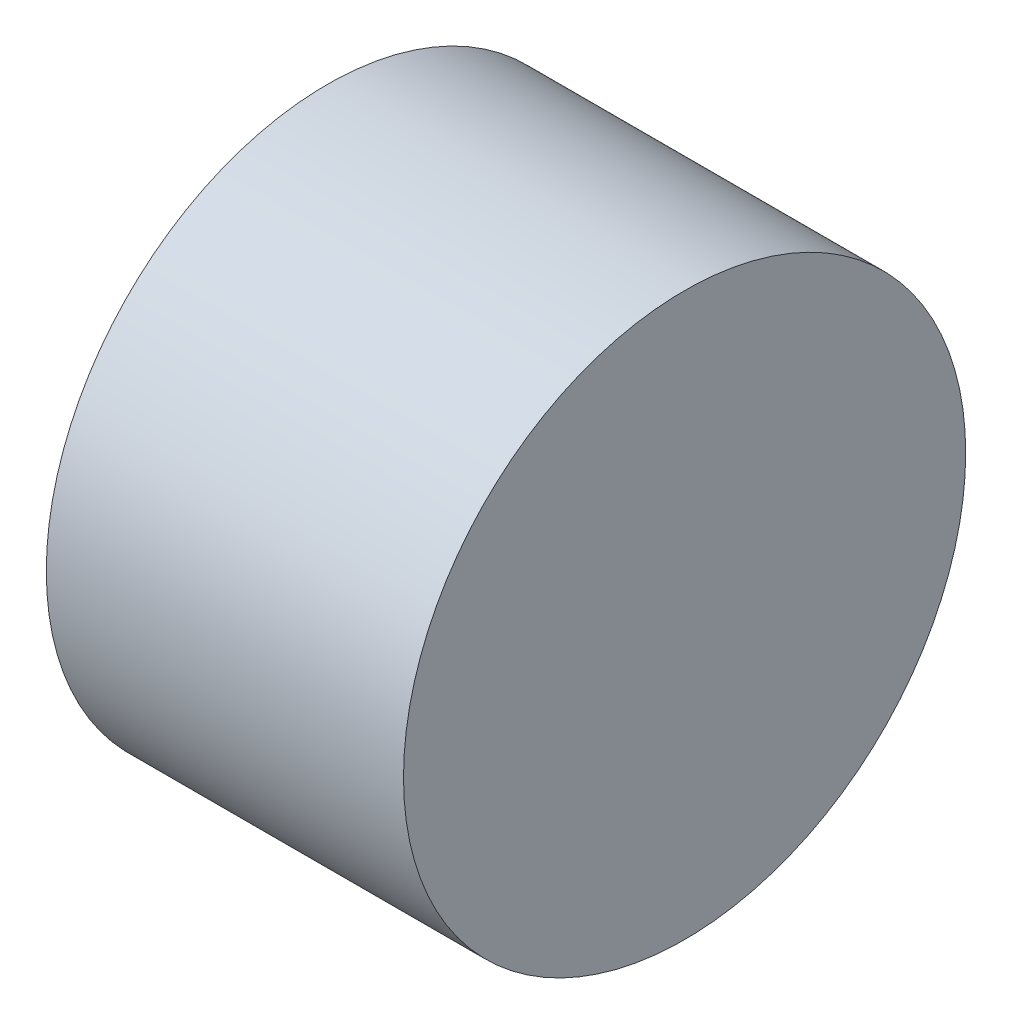
from build123d import *

# Parameters (mm, degrees)
SKETCH1_W          = 23
SKETCH1_H          = 18.1
SKETCH2_R          = 3.71475
CUT_EXTRUDE1_DEPTH = 8.5725


with BuildPart() as part:
    # Sketch1 → Revolve1 (revolve)
    with BuildSketch(Plane.XY):
        with Locations((19.755, 9.05)):
            Rectangle(SKETCH1_W, SKETCH1_H)
    revolve(axis=Axis((8.255, 0, 0), (1, 0, 0)))

    # Sketch2 → Cut-Extrude1 (cut)
    with BuildSketch(Plane.ZY.offset(-8.255)):
        Circle(SKETCH2_R)
    extrude(amount=-CUT_EXTRUDE1_DEPTH, mode=Mode.SUBTRACT)


solid = part.part
